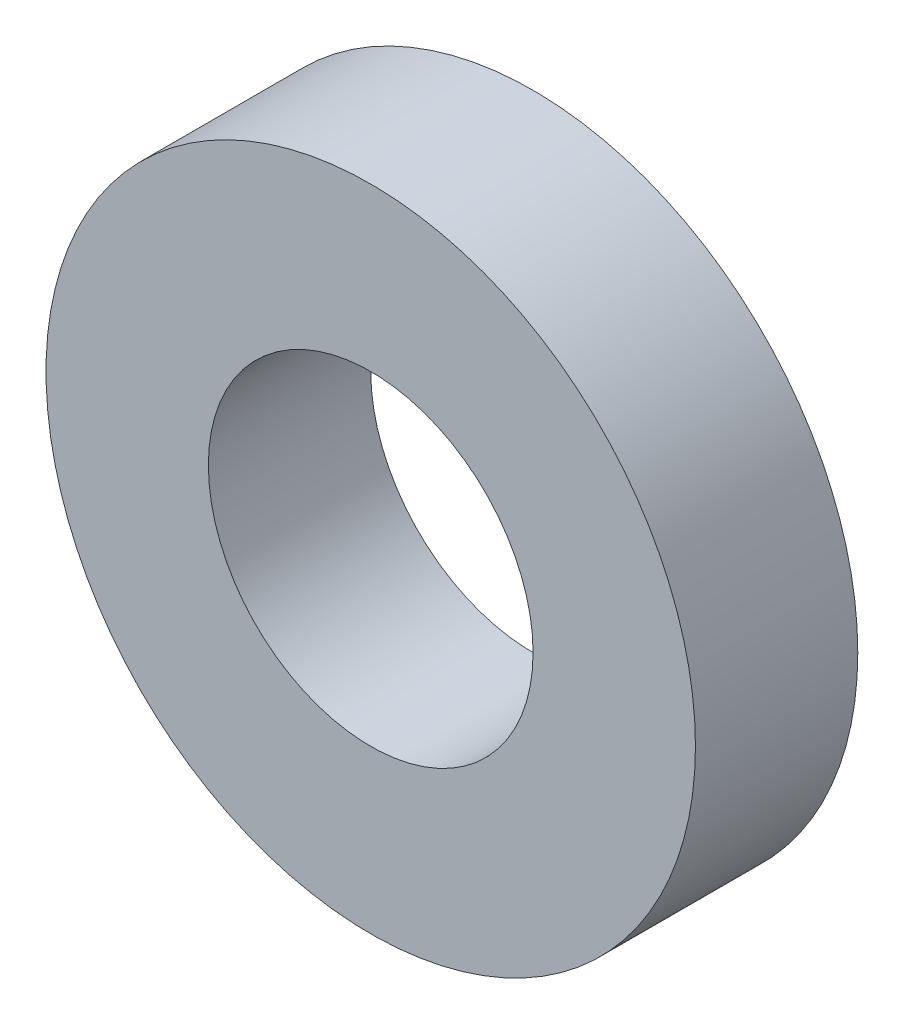
from build123d import *

# Parameters (mm, degrees)
CROQUIS1_W = 0.5
CROQUIS1_H = 0.5


with BuildPart() as part:
    # Croquis1 → Revolución1 (revolve)
    with BuildSketch(Plane(origin=(0, 0, 0), x_dir=(1, 0, 0), z_dir=(0, 1, 0))):
        with Locations((0.75, 0.25)):
            Rectangle(CROQUIS1_W, CROQUIS1_H)
    revolve(axis=Axis((0, 0, 0), (0, 0, -1)))


solid = part.part
